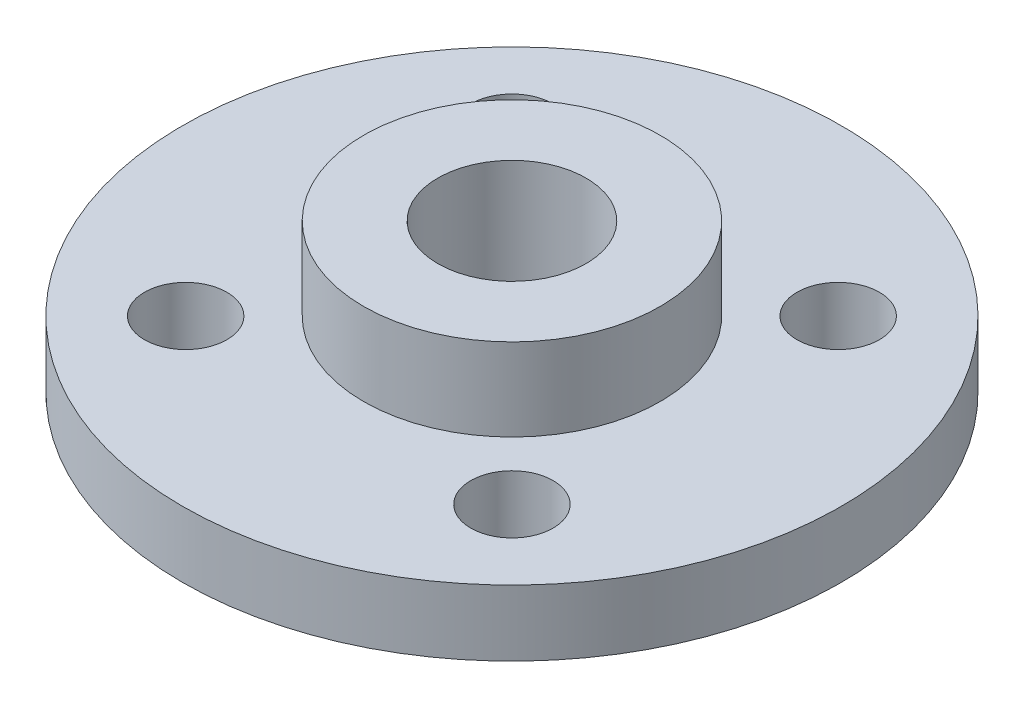
from build123d import *

# Parameters (mm, degrees)
SKETCH1_R           = 10
SKETCH1_R_2         = 1.25
SKETCH1_R_3         = 1.5
BOSS_EXTRUDE1_DEPTH = 2
SKETCH2_R           = 4.5
SKETCH2_R_2         = 1.5
BOSS_EXTRUDE2_DEPTH = 2.5
SKETCH3_R           = 2.25
CUT_EXTRUDE1_DEPTH  = 3.6


with BuildPart() as part:
    # Sketch1 → Boss-Extrude1 (new body)
    with BuildSketch(Plane(origin=(0, 0, 0), x_dir=(1, 0, 0), z_dir=(0, 1, 0))):
        Circle(SKETCH1_R)
        with Locations((-4.949747468, 4.949747468)):
            Circle(SKETCH1_R_2, mode=Mode.SUBTRACT)
        with Locations((4.949747468, 4.949747468)):
            Circle(SKETCH1_R_2, mode=Mode.SUBTRACT)
        with Locations((4.949747468, -4.949747468)):
            Circle(SKETCH1_R_2, mode=Mode.SUBTRACT)
        with Locations((-4.949747468, -4.949747468)):
            Circle(SKETCH1_R_2, mode=Mode.SUBTRACT)
        Circle(SKETCH1_R_3, mode=Mode.SUBTRACT)
    extrude(amount=BOSS_EXTRUDE1_DEPTH)

    # Sketch2 → Boss-Extrude2 (add)
    with BuildSketch(Plane(origin=(0, 2, 0), x_dir=(1, 0, 0), z_dir=(0, 1, 0))):
        Circle(SKETCH2_R)
        Circle(SKETCH2_R_2, mode=Mode.SUBTRACT)
    extrude(amount=BOSS_EXTRUDE2_DEPTH)

    # Sketch3 → Cut-Extrude1 (cut)
    with BuildSketch(Plane(origin=(0, 4.5, 0), x_dir=(1, 0, 0), z_dir=(0, 1, 0))):
        Circle(SKETCH3_R)
    extrude(amount=-CUT_EXTRUDE1_DEPTH, mode=Mode.SUBTRACT)


solid = part.part
